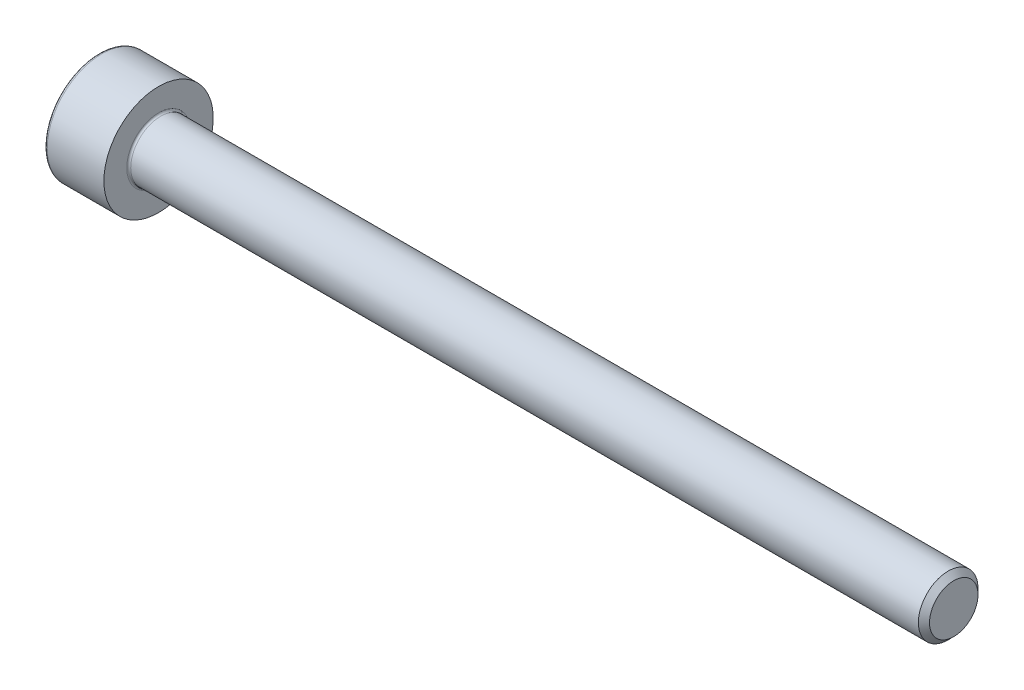
from build123d import *

# Parameters (mm, degrees)
FILLET1_R   = 0.1
FILLET2_R   = 0.15
HEX_2_DEPTH = 1.3


with BuildPart() as part:
    # BodySke → Base-Revolve (revolve)
    with BuildSketch(Plane.XY):
        Polygon((0, 0), (0, 2.75), (3, 2.75), (3, 1.5), (42.7195, 1.5), (43, 1.2195), (43, 0), align=None)
    revolve(axis=Axis((-31.75, 0, 0), (1, 0, 0)))

    # Fillet1
    fillet1_edges = [part.edges().sort_by_distance(p)[0] for p in [
        (3, -1.5, 0),
    ]]
    fillet(fillet1_edges, radius=FILLET1_R)

    # Fillet2
    fillet2_edges = [part.edges().sort_by_distance(p)[0] for p in [
        (0, -2.75, 0),
    ]]
    fillet(fillet2_edges, radius=FILLET2_R)

    # Sketch2 → Hex-PreBroach (revolve, cut)
    with BuildSketch(Plane.XY):
        Polygon((0, 1.28), (1.3, 1.28), (2.039008345, 0), (0, 0), align=None)
    revolve(axis=Axis((0, 0, 0), (1, 0, 0)), mode=Mode.SUBTRACT)

    # Sketch3 → Hex 2 (cut)
    with BuildSketch(Plane(origin=(0, 0, 0), x_dir=(0, 0.5, 0.866025404), z_dir=(-1, 0, 0))):
        Polygon((0.739008345, 1.28), (-0.739008345, 1.28), (-1.478016689, 0), (-0.739008345, -1.28), (0.739008345, -1.28), (1.478016689, 0), align=None)
    extrude(amount=-HEX_2_DEPTH, mode=Mode.SUBTRACT)


solid = part.part
